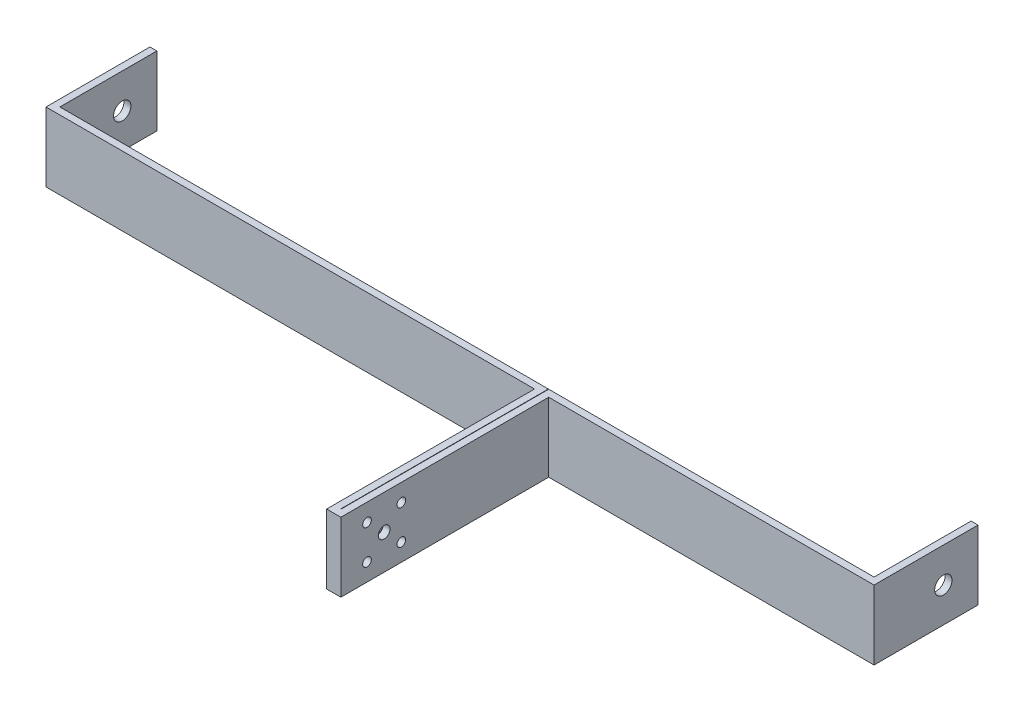
from build123d import *

# Parameters (mm, degrees)
BOSS_EXTRUDE1_DEPTH      = 10
BOSS_EXTRUDE1_DEPTH_BACK = 10
SKETCH2_R                = 2.5
CUT_EXTRUDE1_DEPTH       = 285
SKETCH3_R                = 1.7
SKETCH3_R_2              = 1.25
CUT_EXTRUDE2_DEPTH       = 285


with BuildPart() as part:
    # Sketch1 → Boss-Extrude1 (new, two sides: drawn at the far end of the back side and taken through both)
    with BuildSketch(Plane(origin=(0, 0, 0), x_dir=(1, 0, 0), z_dir=(0, 1, 0)).offset(-BOSS_EXTRUDE1_DEPTH_BACK)):
        Polygon((25.6, -20), (119.5, -20), (119.5, 10), (117.5, 10), (117.5, -18), (23.6, -18), (23.6, -78), (23.5, -78), (23.5, -18), (-117.5, -18), (-117.5, 10), (-119.5, 10), (-119.5, -20), (21.5, -20), (21.5, -80), (25.6, -80), align=None)
    extrude(amount=BOSS_EXTRUDE1_DEPTH + BOSS_EXTRUDE1_DEPTH_BACK)

    # Sketch2 → Cut-Extrude1 (cut)
    with BuildSketch(Plane.ZY.offset(119.5)):
        Circle(SKETCH2_R)
    extrude(amount=-CUT_EXTRUDE1_DEPTH, mode=Mode.SUBTRACT)

    # Sketch3 → Cut-Extrude2 (cut)
    with BuildSketch(Plane(origin=(25.6, 0, 0), x_dir=(0, 0, -1), z_dir=(1, 0, 0))):
        with Locations((-67.5, 0)):
            Circle(SKETCH3_R)
        with Locations((-72.449747468, -4.949747468)):
            Circle(SKETCH3_R_2)
        with Locations((-72.449747468, 4.949747468)):
            Circle(SKETCH3_R_2)
        with Locations((-62.550252532, 4.949747468)):
            Circle(SKETCH3_R_2)
        with Locations((-62.550252532, -4.949747468)):
            Circle(SKETCH3_R_2)
    extrude(amount=-CUT_EXTRUDE2_DEPTH, mode=Mode.SUBTRACT)


solid = part.part
